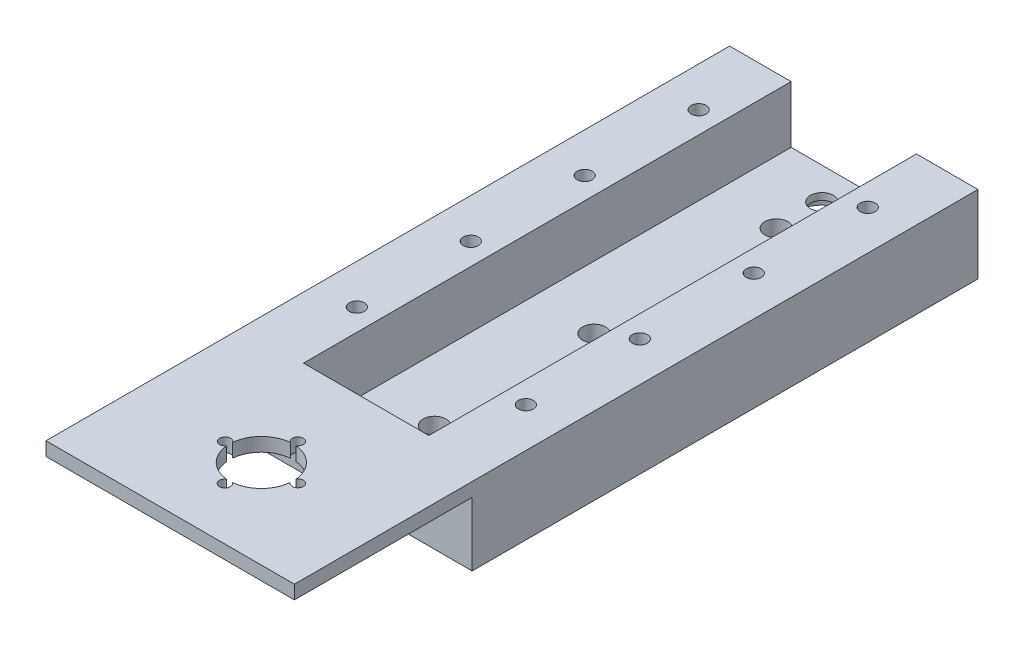
from build123d import *

# Parameters (mm, degrees)
SKETCH1_W                  = 54.5
SKETCH1_H                  = 111
BOSS_EXTRUDE1_DEPTH        = 4.5
SKETCH2_W                  = 13.5
SKETCH2_H                  = 111
BOSS_EXTRUDE2_DEPTH        = 12.5
M4X0_7_TAPPED_HOLE1_D      = 3.3
SKETCH6_W                  = 4
SKETCH6_H                  = 12.5
BOSS_EXTRUDE3_DEPTH        = 37
SKETCH7_W                  = 54.5
SKETCH7_H                  = 3
BOSS_EXTRUDE5_DEPTH        = 39
SKETCH8_R                  = 7
CUT_EXTRUDE1_DEPTH         = 3
M2_CLEARANCE_HOLE1_D       = 2.4
F_8_0_199_DIAMETER_HOLE1_D = 5.0546
SKETCH12_R                 = 5.5
CUT_EXTRUDE3_DEPTH         = 3


with BuildPart() as part:
    # Sketch1 → Boss-Extrude1 (new body)
    with BuildSketch(Plane(origin=(0, 0, 0), x_dir=(1, 0, 0), z_dir=(0, 1, 0))):
        with Locations((-13.399543841, 44.129312584)):
            Rectangle(SKETCH1_W, SKETCH1_H)
    extrude(amount=BOSS_EXTRUDE1_DEPTH)

    # Sketch2 → Boss-Extrude2 (add)
    with BuildSketch(Plane(origin=(0, 4.5, 0), x_dir=(1, 0, 0), z_dir=(0, 1, 0))):
        with Locations((7.100456159, 44.129312584)):
            Rectangle(SKETCH2_W, SKETCH2_H)
        with Locations((-33.899543841, 44.129312584)):
            Rectangle(SKETCH2_W, SKETCH2_H)
    extrude(amount=BOSS_EXTRUDE2_DEPTH)

    # M4x0.7 Tapped Hole1 (through all)
    with Locations(Plane(origin=(-31.949543841, 17, -9.129312584), x_dir=(0, 0, 1), z_dir=(0, 1, 0))):
        with Locations((0, 0), (-25, 0), (-50, 0), (-75, 0), (0, 37.1), (-25, 37.1), (-50, 37.1), (-75, 37.1)):
            Hole(M4X0_7_TAPPED_HOLE1_D / 2)

    # Sketch6 → Boss-Extrude3 (add)
    with BuildSketch(Plane(origin=(-27.149543841, 0, 0), x_dir=(0, 0, -1), z_dir=(1, 0, 0))):
        with Locations((-9.370687416, 10.75)):
            Rectangle(SKETCH6_W, SKETCH6_H)
    extrude(amount=BOSS_EXTRUDE3_DEPTH)

    # Sketch7 → Boss-Extrude5 (add)
    with BuildSketch(Plane.XY.offset(11.370687416)):
        with Locations((-13.399543841, 15.5)):
            Rectangle(SKETCH7_W, SKETCH7_H)
    extrude(amount=BOSS_EXTRUDE5_DEPTH)

    # Sketch8 → Cut-Extrude1 (cut)
    with BuildSketch(Plane(origin=(0, 17, 0), x_dir=(1, 0, 0), z_dir=(0, 1, 0))):
        with Locations((-12.899543841, -30.870687416)):
            Circle(SKETCH8_R)
    extrude(amount=-CUT_EXTRUDE1_DEPTH, mode=Mode.SUBTRACT)

    # M2 Clearance Hole1 (through all)
    with Locations(Plane(origin=(-20.871437118, 17, 30.847906254), x_dir=(0, 0, 1), z_dir=(0, 1, 0))):
        with Locations((0, 0), (-7.977218838, 7.971893277), (8.022781162, 7.971893277), (-0.002806072, 15.940961576)):
            Hole(M2_CLEARANCE_HOLE1_D / 2)

    # #8 (0.199) Diameter Hole1 (through all)
    with Locations(Plane(origin=(-13.399543841, 4.5, 2.370687416), x_dir=(0, 0, 1), z_dir=(0, 1, 0))):
        with Locations((0, 0), (-10, 0), (-45, 0), (-85, 0), (-95, 0)):
            Hole(F_8_0_199_DIAMETER_HOLE1_D / 2)

    # Sketch12 → Cut-Extrude3 (cut)
    with BuildSketch(Plane(origin=(0, 0, 0), x_dir=(-1, 0, 0), z_dir=(0, -1, 0))):
        with Locations((13.399543841, 92.629312584)):
            Circle(SKETCH12_R)
    extrude(amount=-CUT_EXTRUDE3_DEPTH, mode=Mode.SUBTRACT)


solid = part.part
